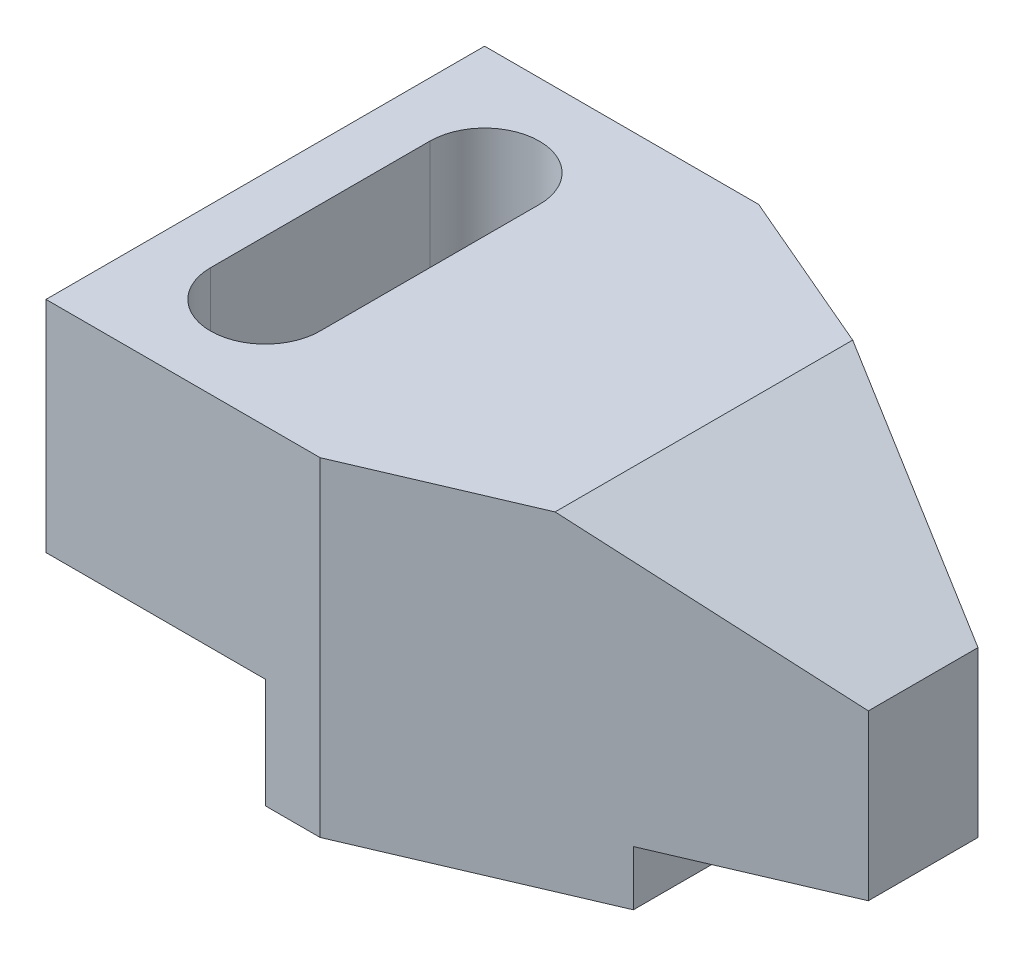
from build123d import *

# Parameters (mm, degrees)
SKETCH1_W           = 40
SKETCH1_H           = 80
SKETCH1_W_2         = 10
BOSS_EXTRUDE1_DEPTH = 60
SKETCH2_W           = 40
SKETCH2_H           = 20
CUT_EXTRUDE1_DEPTH  = 81
CUT_EXTRUDE2_DEPTH  = 10
CUT_EXTRUDE3_DEPTH  = 61
CUT_EXTRUDE4_DEPTH  = 81


with BuildPart() as part:
    # Sketch1 → Boss-Extrude1 (new body)
    with BuildSketch(Plane(origin=(0, 0, 0), x_dir=(1, 0, 0), z_dir=(0, 1, 0))):
        Rectangle(SKETCH1_W, SKETCH1_H)
        Polygon((100, -10), (30, -40), (30, 40), (100, 10), align=None)
        with Locations((25, 0)):
            Rectangle(SKETCH1_W_2, SKETCH1_H)
    extrude(amount=BOSS_EXTRUDE1_DEPTH)

    # Sketch2 → Cut-Extrude1 (cut, through all)
    with BuildSketch(Plane.XY.offset(40)):
        with Locations((0, 10)):
            Rectangle(SKETCH2_W, SKETCH2_H)
    extrude(amount=-CUT_EXTRUDE1_DEPTH, mode=Mode.SUBTRACT)

    # Sketch3 → Cut-Extrude2 (cut)
    with BuildSketch(Plane.XZ):
        Polygon((70, 0), (100, 0), (100, 10), (70, 22.857142857), align=None)
        Polygon((100, -10), (100, 0), (70, 0), (70, -22.857142857), align=None)
    extrude(amount=-CUT_EXTRUDE2_DEPTH, mode=Mode.SUBTRACT)

    # Sketch5 → Cut-Extrude3 (cut, through all)
    with BuildSketch(Plane(origin=(0, 60, 0), x_dir=(1, 0, 0), z_dir=(0, 1, 0))):
        with BuildLine():
            Line((-10, -20), (-10, 20))
            ThreePointArc((-10, 20), (0, 30), (10, 20))
            Line((10, 20), (10, -20))
            ThreePointArc((10, -20), (0, -30), (-10, -20))
        make_face()
    extrude(amount=-CUT_EXTRUDE3_DEPTH, mode=Mode.SUBTRACT)

    # Sketch6 → Cut-Extrude4 (cut, through all)
    with BuildSketch(Plane.XY.offset(40)):
        Polygon((60, 60), (100, 60), (100, 40), align=None)
    extrude(amount=-CUT_EXTRUDE4_DEPTH, mode=Mode.SUBTRACT)


solid = part.part
